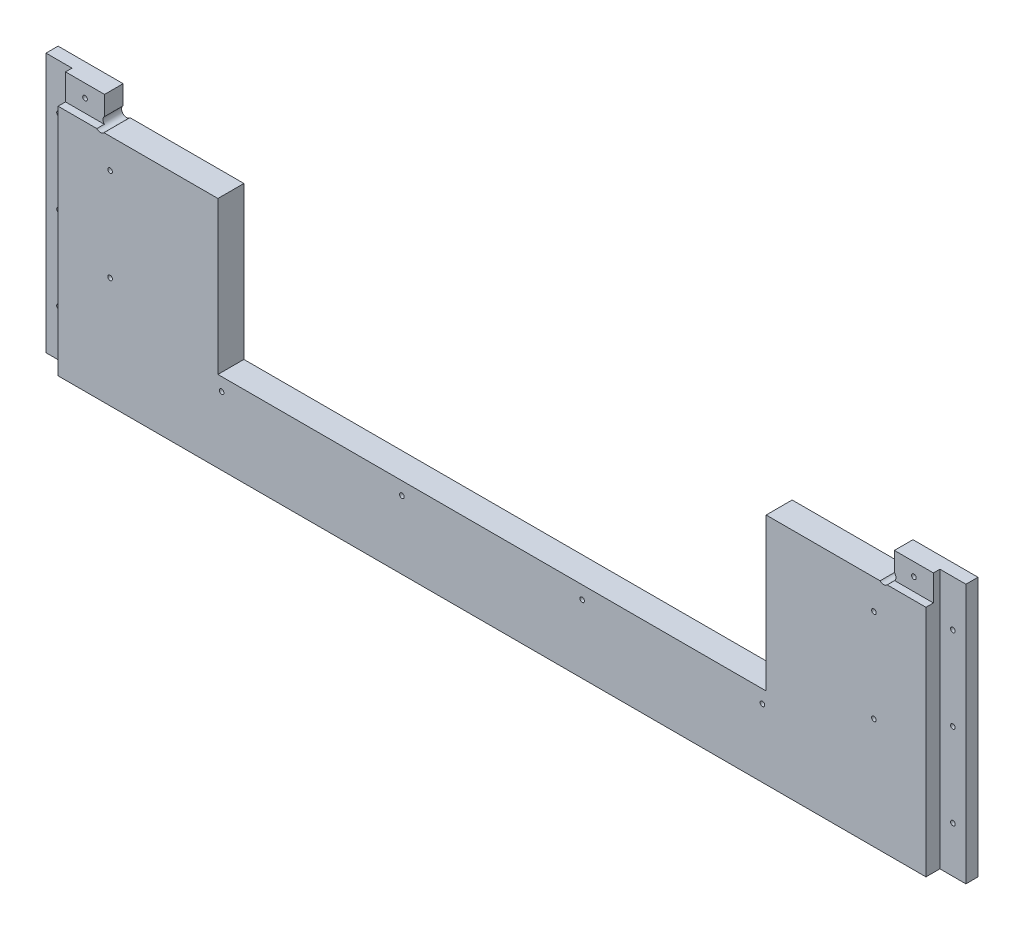
from build123d import *

# Parameters (mm, degrees)
EXTRUDE1_DEPTH     = 17.78
SKETCH3_W          = 44.45
SKETCH3_H          = 17.78
CUT_EXTRUDE1_DEPTH = 5.08
SKETCH4_W          = 17.78
SKETCH4_H          = 177.363711221
CUT_EXTRUDE2_DEPTH = 9.525
SKETCH5_R          = 1.5875
SKETCH5_R_2        = 3.302
CUT_EXTRUDE3_DEPTH = 17.78


with BuildPart() as part:
    # Sketch2 → Extrude1 (new body)
    with BuildSketch(Plane.XY):
        Polygon((12324.291666666, -6347.976211221), (12324.291666666, -6170.6125), (12279.841666666, -6170.6125), (12279.841666666, -6188.3925), (12197.291666666, -6188.3925), (12197.291666666, -6292.5325), (11822.641666666, -6292.5325), (11822.641666666, -6188.3925), (11740.091666666, -6188.3925), (11740.091666666, -6170.6125), (11695.641666666, -6170.6125), (11695.641666666, -6347.976211221), align=None)
    extrude(amount=-EXTRUDE1_DEPTH)

    # Sketch3 → Cut-Extrude1 (cut)
    with BuildSketch(Plane.XY):
        with Locations((11717.866666666, -6179.5025)):
            Rectangle(SKETCH3_W, SKETCH3_H)
        with Locations((12302.066666666, -6179.5025)):
            Rectangle(SKETCH3_W, SKETCH3_H)
    extrude(amount=-CUT_EXTRUDE1_DEPTH, mode=Mode.SUBTRACT)

    # Sketch4 → Cut-Extrude2 (cut)
    with BuildSketch(Plane.XY):
        with Locations((11704.531666666, -6259.294355611)):
            Rectangle(SKETCH4_W, SKETCH4_H)
        with Locations((12315.401666666, -6259.294355611)):
            Rectangle(SKETCH4_W, SKETCH4_H)
    extrude(amount=-CUT_EXTRUDE2_DEPTH, mode=Mode.SUBTRACT)

    # Sketch5 → Cut-Extrude3 (cut)
    with BuildSketch(Plane.XY):
        with Locations((11704.531666666, -6316.444355611)):
            Circle(SKETCH5_R)
        with Locations((11704.531666666, -6259.294355611)):
            Circle(SKETCH5_R)
        with Locations((11704.531666666, -6202.144355611)):
            Circle(SKETCH5_R)
        with Locations((11726.756666666, -6179.5025)):
            Circle(SKETCH5_R)
        with Locations((11748.981666666, -6208.7125)):
            Circle(SKETCH5_R)
        with Locations((11748.981666666, -6272.2125)):
            Circle(SKETCH5_R)
        with Locations((11825.181666666, -6301.4225)):
            Circle(SKETCH5_R)
        with Locations((11948.371666666, -6301.4225)):
            Circle(SKETCH5_R)
        with Locations((12071.561666666, -6301.4225)):
            Circle(SKETCH5_R)
        with Locations((12194.751666666, -6301.4225)):
            Circle(SKETCH5_R)
        with Locations((12315.401666666, -6316.444355611)):
            Circle(SKETCH5_R)
        with Locations((12315.401666666, -6259.294355611)):
            Circle(SKETCH5_R)
        with Locations((12270.951666666, -6272.2125)):
            Circle(SKETCH5_R)
        with Locations((12270.951666666, -6208.7125)):
            Circle(SKETCH5_R)
        with Locations((12315.401666666, -6202.144355611)):
            Circle(SKETCH5_R)
        with Locations((12293.176666666, -6179.5025)):
            Circle(SKETCH5_R)
        with Locations((11742.336730696, -6186.14743597)):
            Circle(SKETCH5_R_2)
        with Locations((12277.596602636, -6186.14743597)):
            Circle(SKETCH5_R_2)
    extrude(amount=-CUT_EXTRUDE3_DEPTH, mode=Mode.SUBTRACT)


solid = part.part
